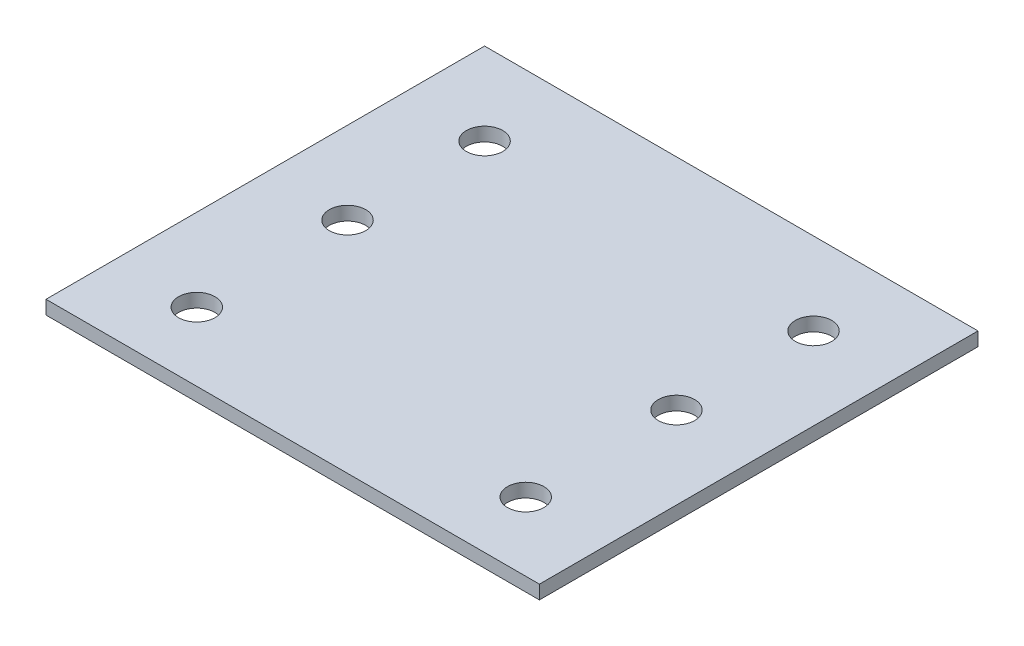
from build123d import *

# Parameters (mm, degrees)
SKETCH1_W                = 114.3
SKETCH1_H                = 101.6
BOSS_EXTRUDE1_DEPTH      = 3.175
F_5_16_CLEARANCE_HOLE2_D = 8.4328


with BuildPart() as part:
    # Sketch1 → Boss-Extrude1 (new body)
    with BuildSketch(Plane(origin=(0, 0, 0), x_dir=(1, 0, 0), z_dir=(0, 1, 0))):
        Rectangle(SKETCH1_W, SKETCH1_H)
    extrude(amount=BOSS_EXTRUDE1_DEPTH)

    # 5/16 Clearance Hole2 (through all)
    with Locations(Plane(origin=(0, 3.175, 0), x_dir=(1, 0, 0), z_dir=(0, 1, 0))):
        with Locations((-38.1, 31.75), (-38.1, 0), (-38.1, -34.925)):
            f_5_16_clearance_hole2 = Hole(F_5_16_CLEARANCE_HOLE2_D / 2)

    # Mirror2: 5/16 Clearance Hole2 across plane
    add(f_5_16_clearance_hole2.mirror(Plane(origin=(0, 0, 0), x_dir=(0, 0, 1), z_dir=(1, 0, 0))), mode=Mode.SUBTRACT)


solid = part.part
